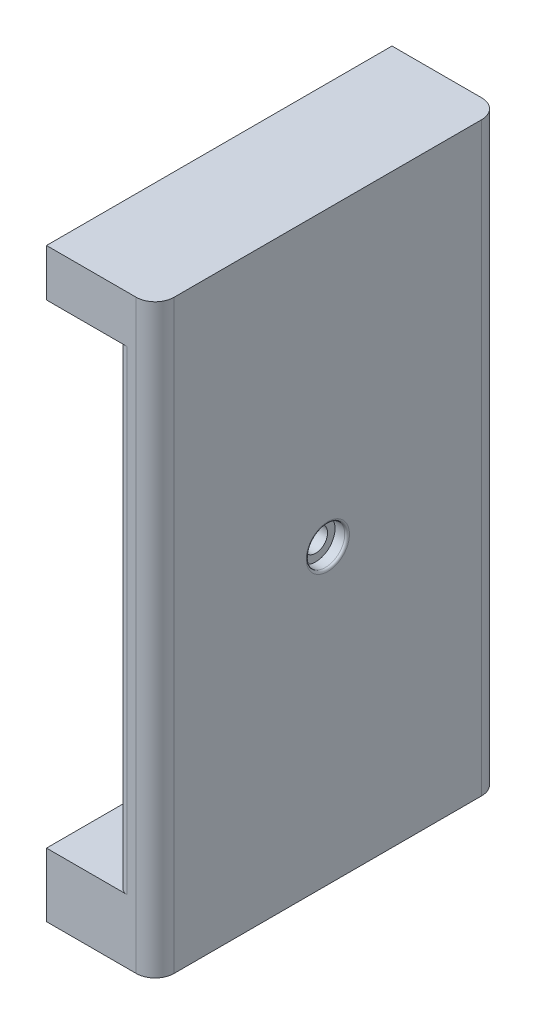
from build123d import *

# Parameters (mm, degrees)
SKETCH1_W           = 12
SKETCH1_H           = 18.25
SKETCH2_R           = 3.7145
CUT_EXTRUDE1_DEPTH  = 8.5725
SKETCH3_W           = 73.152
SKETCH3_H           = 124
BOSS_EXTRUDE1_DEPTH = 8
FILLET1_R           = 4
SKETCH6_R           = 13.15
CUT_EXTRUDE2_DEPTH  = 12
SKETCH12_R          = 4.075
CUT_EXTRUDE6_DEPTH  = 2.56
SKETCH12_6_R        = 2.5
CUT_EXTRUDE7_DEPTH  = 8
FILLET2_R           = 0.5
SKETCH13_W          = 73.152
SKETCH13_H          = 13.5
SKETCH13_H_2        = 10
BOSS_EXTRUDE3_DEPTH = 15
FILLET3_R           = 2
SKETCH14_R          = 3.71375
CUT_EXTRUDE8_DEPTH  = 9.5


with BuildPart() as part:
    # Sketch1 → Revolve1 (revolve)
    with BuildSketch(Plane.XY):
        with Locations((14.255, 9.125)):
            Rectangle(SKETCH1_W, SKETCH1_H)
    revolve(axis=Axis((8.255, 0, 0), (1, 0, 0)))

    # Sketch2 → Cut-Extrude1 (cut)
    with BuildSketch(Plane.ZY.offset(-8.255)):
        Circle(SKETCH2_R)
    extrude(amount=-CUT_EXTRUDE1_DEPTH, mode=Mode.SUBTRACT)

    # Sketch6 → Cut-Extrude2 (cut)
    with BuildSketch(Plane.ZY.offset(-8.255)):
        Circle(SKETCH6_R)
    extrude(amount=-CUT_EXTRUDE2_DEPTH, mode=Mode.SUBTRACT)


with BuildPart() as body_2:
    # Sketch3 → Boss-Extrude1 (new body)
    with BuildSketch(Plane(origin=(20.255, 0, 0), x_dir=(0, 0, -1), z_dir=(1, 0, 0))):
        Rectangle(SKETCH3_W, SKETCH3_H)
    extrude(amount=BOSS_EXTRUDE1_DEPTH)

    # Fillet1
    fillet1_edges = [body_2.edges().sort_by_distance(p)[0] for p in [
        (28.255, 0, -36.576),
        (28.255, 0, 36.576),
    ]]
    fillet(fillet1_edges, radius=FILLET1_R)

    # Sketch12 → Cut-Extrude6 (cut)
    with BuildSketch(Plane(origin=(28.255, 0, 0), x_dir=(0, 0, -1), z_dir=(1, 0, 0))):
        Circle(SKETCH12_R)
    extrude(amount=-CUT_EXTRUDE6_DEPTH, mode=Mode.SUBTRACT)

    # Sketch12_6 → Cut-Extrude7 (cut)
    with BuildSketch(Plane(origin=(28.255, 0, 0), x_dir=(0, 0, -1), z_dir=(1, 0, 0))):
        Circle(SKETCH12_6_R)
    extrude(amount=-CUT_EXTRUDE7_DEPTH, mode=Mode.SUBTRACT)

    # Fillet2
    fillet2_edges = [body_2.edges().sort_by_distance(p)[0] for p in [
        (28.255, 0, 4.075),
    ]]
    fillet(fillet2_edges, radius=FILLET2_R)


with BuildPart() as part_1:
    add(part.part)

    # Combine1: union body 2
    add(body_2.part)

    # Sketch13 → Boss-Extrude3 (add)
    with BuildSketch(Plane.ZY.offset(-20.255)):
        with Locations((0, -55.25)):
            Rectangle(SKETCH13_W, SKETCH13_H)
        with Locations((0, 57)):
            Rectangle(SKETCH13_W, SKETCH13_H_2)
    extrude(amount=BOSS_EXTRUDE3_DEPTH)

    # Fillet3
    fillet3_edges = [part_1.edges().sort_by_distance(p)[0] for p in [
        (20.255, -18.25, 0),
        (20.255, 1.75, 36.576),
        (20.255, 1.75, -36.576),
    ]]
    fillet(fillet3_edges, radius=FILLET3_R)

    # Sketch14 → Cut-Extrude8 (cut)
    with BuildSketch(Plane.XZ.offset(62)):
        with Locations((18.52, 12.75)):
            Circle(SKETCH14_R)
        with Locations((18.52, -12.75)):
            Circle(SKETCH14_R)
    extrude(amount=-CUT_EXTRUDE8_DEPTH, mode=Mode.SUBTRACT)


solid = part_1.part
